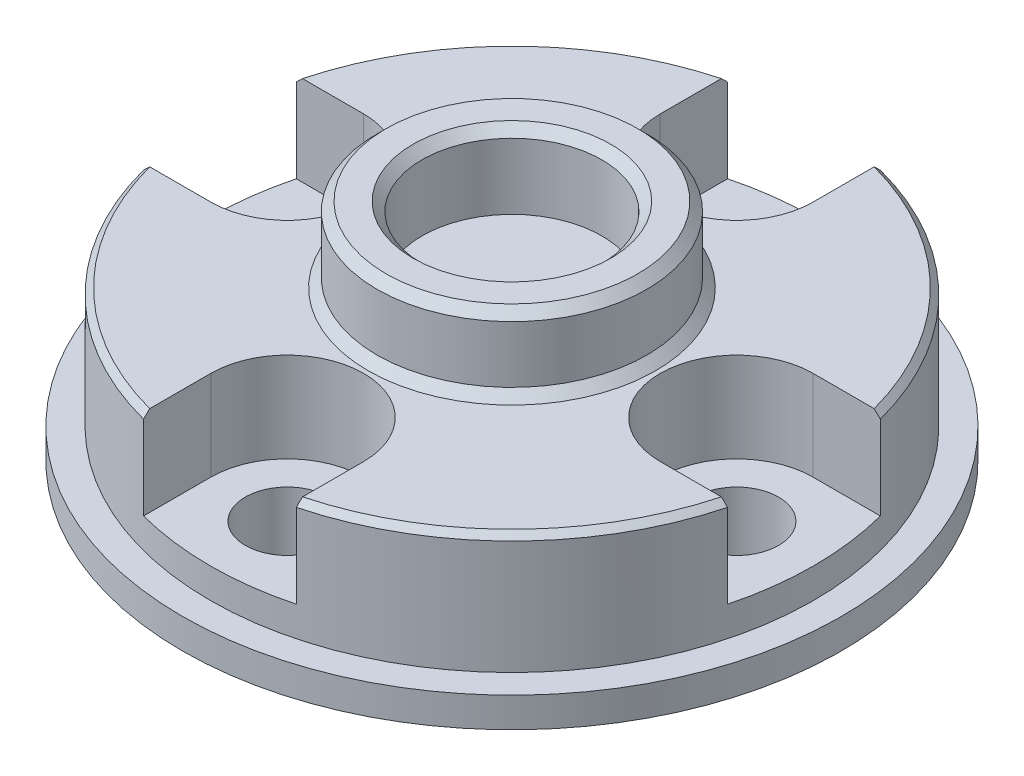
from build123d import *

# Parameters (mm, degrees)
SKETCH1_R           = 11
BOSS_EXTRUDE1_DEPTH = 1
SKETCH2_R           = 10.075
BOSS_EXTRUDE2_DEPTH = 4
CHAMFER1_SIZE       = 0.2
SKETCH3_R           = 1.4
CUT_EXTRUDE1_DEPTH  = 6
CUT_EXTRUDE2_DEPTH  = 3
SKETCH5_R           = 4.5
BOSS_EXTRUDE3_DEPTH = 2.5
SKETCH6_R           = 3
CUT_EXTRUDE3_DEPTH  = 2.5
CHAMFER2_SIZE       = 0.3


with BuildPart() as part:
    # Sketch1 → Boss-Extrude1 (new body)
    with BuildSketch(Plane(origin=(0, 0, 0), x_dir=(1, 0, 0), z_dir=(0, 1, 0))):
        Circle(SKETCH1_R)
    extrude(amount=BOSS_EXTRUDE1_DEPTH)

    # Sketch2 → Boss-Extrude2 (add)
    with BuildSketch(Plane(origin=(0, 1, 0), x_dir=(1, 0, 0), z_dir=(0, 1, 0))):
        Circle(SKETCH2_R)
    extrude(amount=BOSS_EXTRUDE2_DEPTH)

    # Chamfer1
    chamfer1_edges = [part.edges().sort_by_distance(p)[0] for p in [
        (-10.075, 5, 0),
    ]]
    chamfer(chamfer1_edges, length=CHAMFER1_SIZE)

    # Sketch3 → Cut-Extrude1 (cut, through all)
    with BuildSketch(Plane(origin=(0, 5, 0), x_dir=(1, 0, 0), z_dir=(0, 1, 0))):
        with Locations((0, 7.5)):
            Circle(SKETCH3_R)
        with Locations((7.5, 0)):
            Circle(SKETCH3_R)
        with Locations((0, -7.5)):
            Circle(SKETCH3_R)
        with Locations((-7.5, 0)):
            Circle(SKETCH3_R)
    extrude(amount=-CUT_EXTRUDE1_DEPTH, mode=Mode.SUBTRACT)

    # Sketch4 → Cut-Extrude2 (cut)
    with BuildSketch(Plane(origin=(0, 5, 0), x_dir=(1, 0, 0), z_dir=(0, 1, 0))):
        with BuildLine():
            Line((-2.55, 7.5), (-2.55, 9.746954653))
            ThreePointArc((-2.55, 9.746954653), (0, 10.075), (2.55, 9.746954653))
            Line((2.55, 9.746954653), (2.55, 7.5))
            ThreePointArc((2.55, 7.5), (0, 4.95), (-2.55, 7.5))
        make_face()
        with BuildLine():
            Line((7.5, -2.55), (9.746954653, -2.55))
            ThreePointArc((9.746954653, -2.55), (10.075, 0), (9.746954653, 2.55))
            Line((9.746954653, 2.55), (7.5, 2.55))
            ThreePointArc((7.5, 2.55), (4.95, 0), (7.5, -2.55))
        make_face()
        with BuildLine():
            Line((-2.55, -7.5), (-2.55, -9.746954653))
            ThreePointArc((-2.55, -9.746954653), (0, -10.075), (2.55, -9.746954653))
            Line((2.55, -9.746954653), (2.55, -7.5))
            ThreePointArc((2.55, -7.5), (0, -4.95), (-2.55, -7.5))
        make_face()
        with BuildLine():
            Line((-7.5, 2.55), (-9.746954653, 2.55))
            ThreePointArc((-9.746954653, 2.55), (-10.075, 0), (-9.746954653, -2.55))
            Line((-9.746954653, -2.55), (-7.5, -2.55))
            ThreePointArc((-7.5, -2.55), (-4.95, 0), (-7.5, 2.55))
        make_face()
    extrude(amount=-CUT_EXTRUDE2_DEPTH, mode=Mode.SUBTRACT)

    # Sketch5 → Boss-Extrude3 (add)
    with BuildSketch(Plane(origin=(0, 5, 0), x_dir=(1, 0, 0), z_dir=(0, 1, 0))):
        Circle(SKETCH5_R)
    extrude(amount=BOSS_EXTRUDE3_DEPTH)

    # Sketch6 → Cut-Extrude3 (cut)
    with BuildSketch(Plane(origin=(0, 7.5, 0), x_dir=(1, 0, 0), z_dir=(0, 1, 0))):
        Circle(SKETCH6_R)
    extrude(amount=-CUT_EXTRUDE3_DEPTH, mode=Mode.SUBTRACT)

    # Chamfer2
    chamfer2_edges = [part.edges().sort_by_distance(p)[0] for p in [
        (-4.5, 5, 0),
        (-4.5, 7.5, 0),
        (-3, 7.5, 0),
    ]]
    chamfer(chamfer2_edges, length=CHAMFER2_SIZE)


solid = part.part
